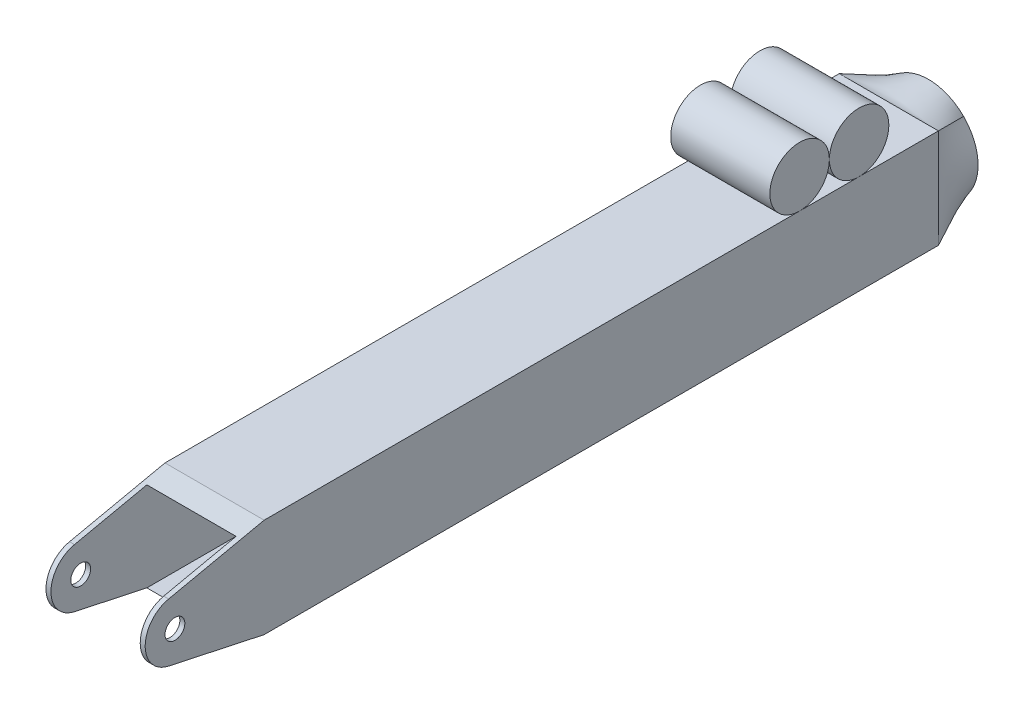
from build123d import *

# Parameters (mm, degrees)
BOSS_EXTRUDE1_START   = 25.4
SKETCH1_W             = 63.5
SKETCH1_H             = 63.5
SKETCH1_W_2           = 57.15
SKETCH1_H_2           = 57.15
BOSS_EXTRUDE1_DEPTH   = 508
SKETCH3_W             = 63.5
SKETCH3_H             = 63.5
SKETCH4_R             = 6.35
CUT_EXTRUDE1_DEPTH    = 539.103960698
SKETCH5_R             = 19.05
BOSS_EXTRUDE2_DEPTH   = 63.5
BOSS_EXTRUDE2_2_DEPTH = 63.5


with BuildPart() as part:
    # Sketch1 → Boss-Extrude1 (new body)
    with BuildSketch(Plane.XY.offset(BOSS_EXTRUDE1_START)):
        Rectangle(SKETCH1_W, SKETCH1_H)
        Rectangle(SKETCH1_W_2, SKETCH1_H_2, mode=Mode.SUBTRACT)
    extrude(amount=BOSS_EXTRUDE1_DEPTH)

    # Sketch2 for Loft1 → Loft1 section 0
    with BuildSketch(Plane.XY):
        with BuildLine():
            # circular arc as an exact rational Bezier (weights 1, cos(half-angle), 1)
            Bezier((-22.450640303, 22.450640303), (-44.901280604, 0), (-22.450640303, -22.450640303), weights=[1, 0.707106781, 1])
            Bezier((-22.450640303, -22.450640303), (0, -44.901280604), (22.450640303, -22.450640303), weights=[1, 0.707106781, 1])
            Bezier((22.450640303, -22.450640303), (44.901280604, 0), (22.450640303, 22.450640303), weights=[1, 0.707106781, 1])
            Bezier((22.450640303, 22.450640303), (0, 44.901280604), (-22.450640303, 22.450640303), weights=[1, 0.707106781, 1])
        make_face()
    # Sketch3 → Loft1 section 1
    with BuildSketch(Plane(origin=(0, 0, 25.4), x_dir=(-1, 0, 0), z_dir=(0, 0, -1))):
        Rectangle(SKETCH3_W, SKETCH3_H)
    loft()

    # Sketch4 → Cut-Extrude1 (cut, through all)
    with BuildSketch(Plane(origin=(31.75, 0, 0), x_dir=(0, 0, -1), z_dir=(1, 0, 0))):
        with BuildLine():
            ThreePointArc((-518.347676468, -18.625817643), (-529.166515054, -11.973862436), (-533.4, 0))
            Line((-533.4, 0), (-533.4, -31.75))
            Line((-533.4, -31.75), (-457.2, -31.75))
            Line((-457.2, -31.75), (-518.347676468, -18.625817643))
        make_face()
        with BuildLine():
            ThreePointArc((-533.4, 0), (-529.166515054, 11.973862436), (-518.347676468, 18.625817643))
            Line((-518.347676468, 18.625817643), (-457.2, 31.75))
            Line((-457.2, 31.75), (-533.4, 31.75))
            Line((-533.4, 31.75), (-533.4, 0))
        make_face()
        with Locations((-514.35, 0)):
            Circle(SKETCH4_R)
    extrude(amount=-CUT_EXTRUDE1_DEPTH, mode=Mode.SUBTRACT)


with BuildPart() as body_2:
    # Sketch5 → Boss-Extrude2 (new body)
    with BuildSketch(Plane(origin=(31.75, 0, 0), x_dir=(0, 0, -1), z_dir=(1, 0, 0))):
        with Locations((-76.2, 50.8)):
            Circle(SKETCH5_R)
    extrude(amount=-BOSS_EXTRUDE2_DEPTH)


with BuildPart() as body_3:
    # Sketch5 → Boss-Extrude2 2 (new body)
    with BuildSketch(Plane(origin=(31.75, 0, 0), x_dir=(0, 0, -1), z_dir=(1, 0, 0))):
        with Locations((-114.3, 50.8)):
            Circle(SKETCH5_R)
    extrude(amount=-BOSS_EXTRUDE2_2_DEPTH)


solid = Compound([part.part, body_2.part, body_3.part])
